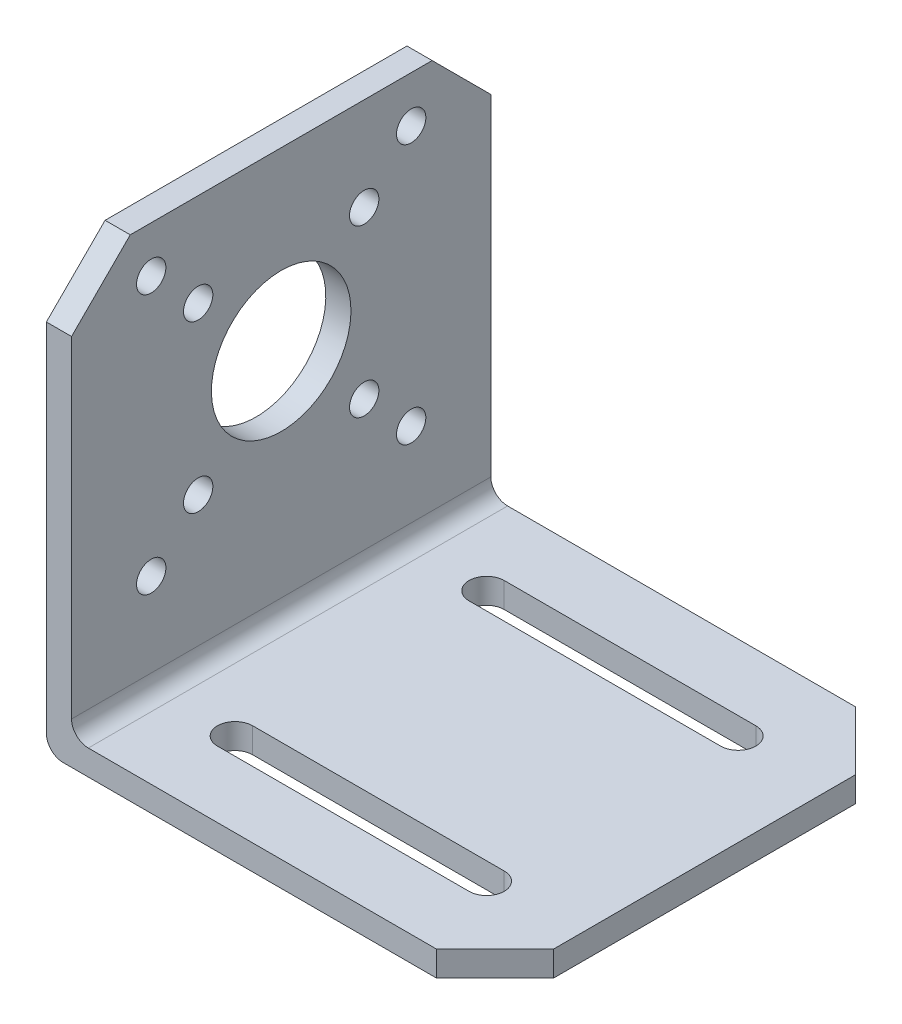
from build123d import *

# Parameters (mm, degrees)
BOSS_EXTRUDE1_DEPTH = 50
SKETCH2_R           = 8.320074994
SKETCH2_R_2         = 1.75
CUT_EXTRUDE1_DEPTH  = 4
CHAMFER1_SIZE       = 7
CHAMFER2_SIZE       = 7
CUT_EXTRUDE2_DEPTH  = 50


with BuildPart() as part:
    # Sketch1 → Boss-Extrude1 (new body)
    with BuildSketch(Plane.XY):
        with BuildLine():
            Line((0, 51.5), (0, 2))
            ThreePointArc((0, 2), (0.585786438, 0.585786438), (2, 0))
            Line((2, 0), (53.5, 0))
            Line((53.5, 0), (53.5, 3))
            Line((53.5, 3), (5, 3))
            ThreePointArc((5, 3), (3.585786438, 3.585786438), (3, 5))
            Line((3, 5), (3, 51.5))
            Line((3, 51.5), (0, 51.5))
        make_face()
    extrude(amount=BOSS_EXTRUDE1_DEPTH)

    # Sketch2 → Cut-Extrude1 (cut, through all)
    with BuildSketch(Plane(origin=(3, 0, 0), x_dir=(0, 0, -1), z_dir=(1, 0, 0))):
        with Locations((-25, 30.5)):
            Circle(SKETCH2_R)
        with Locations((-34.899494937, 40.399494937)):
            Circle(SKETCH2_R_2)
        with Locations((-15.100505063, 40.399494937)):
            Circle(SKETCH2_R_2)
        with Locations((-15.100505063, 20.600505063)):
            Circle(SKETCH2_R_2)
        with Locations((-34.899494937, 20.600505063)):
            Circle(SKETCH2_R_2)
        with Locations((-40.5, 46)):
            Circle(SKETCH2_R_2)
        with Locations((-9.5, 46)):
            Circle(SKETCH2_R_2)
        with Locations((-40.5, 15)):
            Circle(SKETCH2_R_2)
        with Locations((-9.5, 15)):
            Circle(SKETCH2_R_2)
    extrude(amount=-CUT_EXTRUDE1_DEPTH, mode=Mode.SUBTRACT)

    # Chamfer1
    chamfer1_edges = [part.edges().sort_by_distance(p)[0] for p in [
        (1.5, 51.5, 0),
    ]]
    chamfer(chamfer1_edges, length=CHAMFER1_SIZE)

    # Chamfer2
    chamfer2_edges = [part.edges().sort_by_distance(p)[0] for p in [
        (53.5, 1.5, 50),
        (1.5, 51.5, 50),
        (53.5, 1.5, 0),
    ]]
    chamfer(chamfer2_edges, length=CHAMFER2_SIZE)

    # Sketch5 → Cut-Extrude2 (cut)
    with BuildSketch(Plane(origin=(0, 3, 0), x_dir=(1, 0, 0), z_dir=(0, 1, 0))):
        with BuildLine():
            Line((12.5, -7.9), (42.5, -7.9))
            ThreePointArc((42.5, -7.9), (44.6, -10), (42.5, -12.1))
            Line((42.5, -12.1), (12.5, -12.1))
            ThreePointArc((12.5, -12.1), (10.4, -10), (12.5, -7.9))
        make_face()
        with BuildLine():
            Line((12.5, -42.1), (42.5, -42.1))
            ThreePointArc((42.5, -42.1), (44.6, -40), (42.5, -37.9))
            Line((42.5, -37.9), (12.5, -37.9))
            ThreePointArc((12.5, -37.9), (10.4, -40), (12.5, -42.1))
        make_face()
    extrude(amount=-CUT_EXTRUDE2_DEPTH, mode=Mode.SUBTRACT)


solid = part.part
